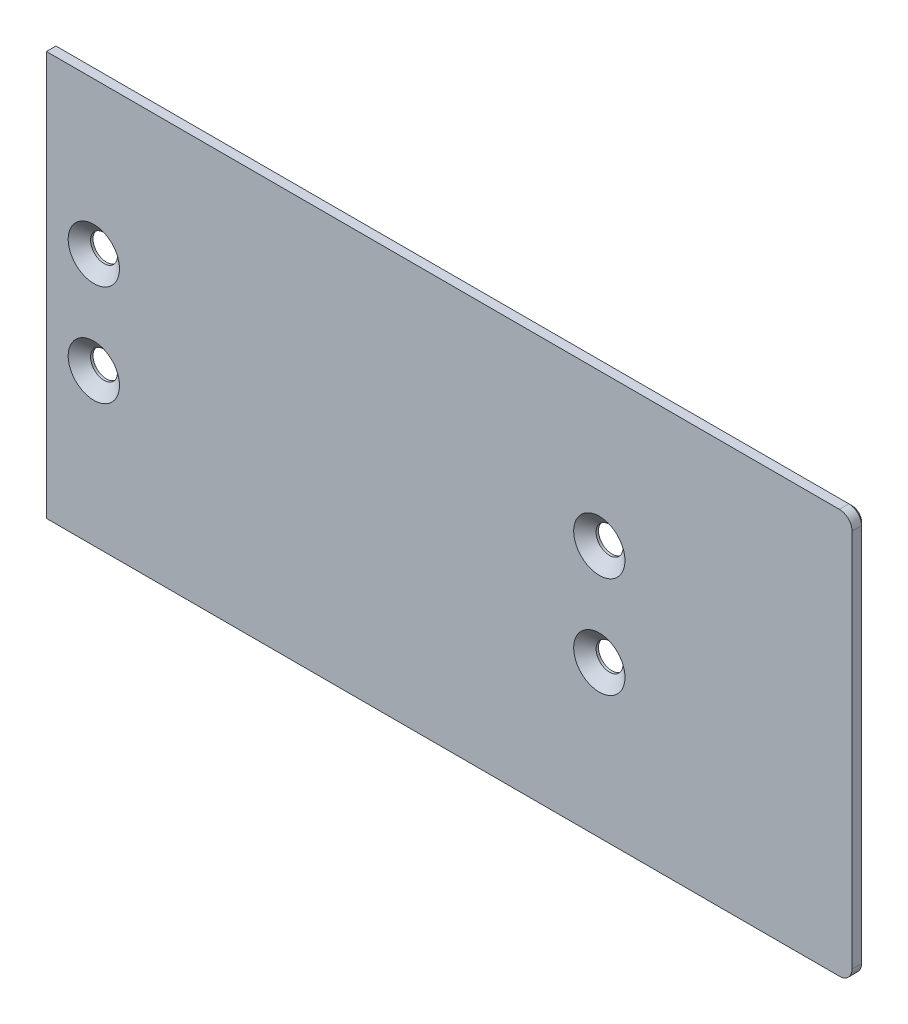
from build123d import *

# Parameters (mm, degrees)
SKETCH1_W                                   = 202.40625
SKETCH1_H                                   = 3.175
BOSS_EXTRUDE1_DEPTH                         = 101.6
CSK_FOR_1_4_FLAT_HEAD_MACHINE_SCREW_2_COUNT = 2
CSK_FOR_1_4_FLAT_HEAD_MACHINE_SCREW_2_PITCH = 25.4
CSK_FOR_1_4_FLAT_HEAD_MACHINE_SCREW_3_COUNT = 2
CSK_FOR_1_4_FLAT_HEAD_MACHINE_SCREW_3_PITCH = 129.515095645
CSK_FOR_1_4_FLAT_HEAD_MACHINE_SCREW_4_COUNT = 2
CSK_FOR_1_4_FLAT_HEAD_MACHINE_SCREW_4_PITCH = 127
CUT_EXTRUDE1_DEPTH                          = 4.175
CHAMFER1_SIZE                               = 0.7874


with BuildPart() as part:
    # Sketch1 → Boss-Extrude1 (new body)
    with BuildSketch(Plane(origin=(0, 0, 0), x_dir=(1, 0, 0), z_dir=(0, 1, 0))):
        with Locations((101.203125, -1.5875)):
            Rectangle(SKETCH1_W, SKETCH1_H)
    extrude(amount=-BOSS_EXTRUDE1_DEPTH)

    # Sketch15 → CSK for 1/4 Flat Head Machine Screw (100)5 (revolve, cut)
    with BuildSketch(Plane(origin=(11.90625, -38.1, 3.175), x_dir=(0, -1, 0), z_dir=(1, 0, 0))):
        Polygon((0, 0), (0, 3.175), (3.3782, 3.175), (3.3782, 2.568232241), (6.4389, 0), align=None)
    csk_for_1_4_flat_head_machine_screw_100 = revolve(axis=Axis((11.90625, -38.1, 9.525), (0, 0, -1)), mode=Mode.SUBTRACT)

    # CSK for 1_4 Flat Head Machine Screw  2: CSK for 1/4 Flat Head Machine Screw (100)5 ×2
    with Locations(*[(0, -i * CSK_FOR_1_4_FLAT_HEAD_MACHINE_SCREW_2_PITCH, 0) for i in range(1, CSK_FOR_1_4_FLAT_HEAD_MACHINE_SCREW_2_COUNT)]):
        add(csk_for_1_4_flat_head_machine_screw_100, mode=Mode.SUBTRACT)

    # CSK for 1_4 Flat Head Machine Screw  3: CSK for 1/4 Flat Head Machine Screw (100)5 ×2
    with Locations(*[Vector(0.980580676, -0.196116135, 0) * (i * CSK_FOR_1_4_FLAT_HEAD_MACHINE_SCREW_3_PITCH) for i in range(1, CSK_FOR_1_4_FLAT_HEAD_MACHINE_SCREW_3_COUNT)]):
        add(csk_for_1_4_flat_head_machine_screw_100, mode=Mode.SUBTRACT)

    # CSK for 1_4 Flat Head Machine Screw  4: CSK for 1/4 Flat Head Machine Screw (100)5 ×2
    with Locations(*[(i * CSK_FOR_1_4_FLAT_HEAD_MACHINE_SCREW_4_PITCH, 0, 0) for i in range(1, CSK_FOR_1_4_FLAT_HEAD_MACHINE_SCREW_4_COUNT)]):
        add(csk_for_1_4_flat_head_machine_screw_100, mode=Mode.SUBTRACT)

    # Sketch17 → Cut-Extrude1 (cut, through all)
    with BuildSketch(Plane.XY.offset(3.175)):
        with BuildLine():
            Line((202.40625, -3.175), (202.40625, 0))
            Line((202.40625, 0), (199.23125, 0))
            ThreePointArc((199.23125, 0), (201.47631403, -0.92993597), (202.40625, -3.175))
        make_face()
        with BuildLine():
            Line((202.40625, -98.425), (202.40625, -101.6))
            Line((202.40625, -101.6), (199.23125, -101.6))
            ThreePointArc((199.23125, -101.6), (201.47631403, -100.67006403), (202.40625, -98.425))
        make_face()
    extrude(amount=-CUT_EXTRUDE1_DEPTH, mode=Mode.SUBTRACT)

    # Chamfer1
    chamfer1_edges = [part.edges().sort_by_distance(p)[0] for p in [
        (99.615625, 0, 0),
        (99.615625, -101.6, 0),
        (202.40625, -50.8, 0),
        (201.47631403, -0.92993597, 0),
        (201.47631403, -100.67006403, 0),
        (0, -50.8, 0),
    ]]
    chamfer(chamfer1_edges, length=CHAMFER1_SIZE)


solid = part.part
